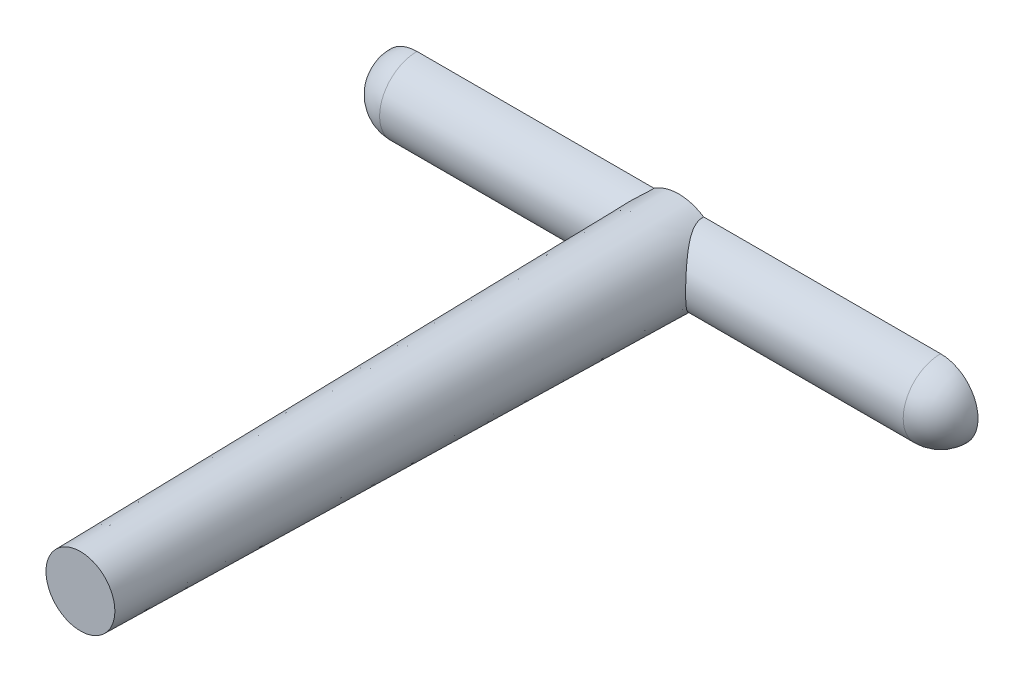
from build123d import *

# Parameters (mm, degrees)
REVOLVE1_ANGLE = 180
SKETCH2_R      = 3
EXTRUDE1_DEPTH = 40
EXTRUDE1_TAPER = 1


with BuildPart() as part:
    # Sketch1 → Revolve1 (revolve)
    with BuildSketch(Plane.XY):
        with BuildLine():
            Line((-20, 0), (20, 0))
            ThreePointArc((20, 0), (19.267766953, 1.767766953), (17.5, 2.5))
            Line((17.5, 2.5), (-17.5, 2.5))
            ThreePointArc((-17.5, 2.5), (-19.267766953, 1.767766953), (-20, 0))
        make_face()
    revolve(axis=Axis((-20, 0, 0), (1, 0, 0)), revolution_arc=REVOLVE1_ANGLE)

    # Sketch2 → Extrude1 (add)
    with BuildSketch(Plane(origin=(0, 0, 0), x_dir=(-1, 0, 0), z_dir=(0, 0, -1))):
        Circle(SKETCH2_R)
    extrude(amount=-EXTRUDE1_DEPTH, taper=EXTRUDE1_TAPER)


solid = part.part
